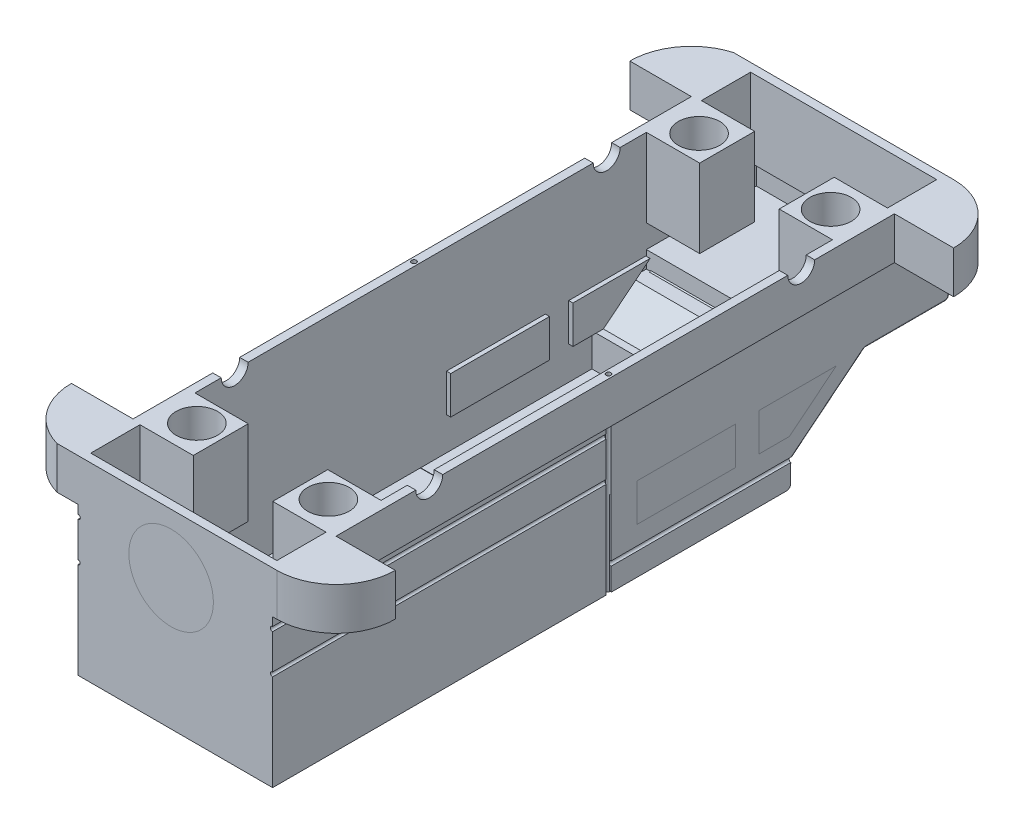
from build123d import *

# Parameters (mm, degrees)
BOSS_EXTRUDE1_DEPTH      = 12.7
SKETCH3_R                = 4.039553008
CUT_EXTRUDE1_DEPTH       = 80.451479119
SKETCH4_R                = 6.227777938
CUT_EXTRUDE3_DEPTH       = 25.4
SKETCH5_W                = 58.42
SKETCH5_H                = 101.6
BOSS_EXTRUDE2_DEPTH      = 19.05
SKETCH6_W                = 58.42
SKETCH6_H                = 76.2
BOSS_EXTRUDE3_DEPTH      = 25.4
FILLET1_R                = 1.27
SKETCH10_W               = 58.42
SKETCH10_H               = 101.6
BOSS_EXTRUDE4_DEPTH      = 19.05
SKETCH11_W               = 50.8
SKETCH11_H               = 91.44
CUT_EXTRUDE5_DEPTH       = 6.35
SKETCH12_W               = 55.88
SKETCH12_H               = 135.54394496
CUT_EXTRUDE6_DEPTH       = 20.32
SKETCH13_W               = 55.88
SKETCH13_H               = 14.77802752
CUT_EXTRUDE7_DEPTH       = 22.86
CUT_EXTRUDE8_DEPTH       = 79.181479119
SKETCH14_W               = 48.26
SKETCH14_H               = 43.785724941
CUT_EXTRUDE9_DEPTH       = 2.54
SKETCH15_W               = 55.88
SKETCH15_H               = 13.826247504
CUT_EXTRUDE10_DEPTH      = 15.24
SKETCH17_W               = 55.57516164
SKETCH17_H               = 46.325724976
CUT_EXTRUDE12_DEPTH      = 33.02
SKETCH20_W               = 55.57516164
SKETCH20_H               = 2.54
CUT_EXTRUDE13_DEPTH      = 15.24
CUT_EXTRUDE14_DEPTH      = 60.96
CUT_EXTRUDE15_DEPTH      = 79.181479119
SKETCH25_W               = 53.34
SKETCH25_H               = 23.50784169
BOSS_EXTRUDE9_DEPTH      = 2.54
BOSS_EXTRUDE10_DEPTH     = 2.54
BOSS_EXTRUDE11_DEPTH     = 2.54
SKETCH30_R               = 0.634743881
SKETCH30_R_2             = 0.669932812
CUT_EXTRUDE22_DEPTH      = 100.33
SKETCH33_R               = 0.704596327
CUT_EXTRUDE23_DEPTH      = 26.4
CUT_EXTRUDE23_DEPTH_BACK = 32.75
SKETCH34_R               = 0.682956923
CUT_EXTRUDE24_DEPTH      = 200.66
SKETCH29_W               = 29.660369153
SKETCH29_H               = 11.320366442
CUT_EXTRUDE25_DEPTH      = 79.181479119
SKETCH38_W               = 29.660369153
SKETCH38_H               = 11.320366442
BOSS_EXTRUDE13_DEPTH     = 2.54
SKETCH39_W               = 29.660369153
SKETCH39_H               = 11.320366442
BOSS_EXTRUDE14_DEPTH     = 2.54
FILLET2_R                = 2.54
FILLET4_R                = 0.254
FILLET5_R                = 1.27
FILLET6_R                = 1.27
SKETCH43_W               = 10.2616
SKETCH43_H               = 25.4
CUT_EXTRUDE30_DEPTH      = 0.508
FILLET7_R                = 0.508
FILLET8_R                = 0.508
BOSS_EXTRUDE15_DEPTH     = 25.4
SKETCH46_W               = 50.8
SKETCH46_H               = 93.865209379
CUT_EXTRUDE31_DEPTH      = 2.54
SKETCH47_R               = 0.704596327
SKETCH47_R_2             = 0.736772129
CUT_EXTRUDE32_DEPTH      = 58.1500001
SKETCH49_W               = 55.88
SKETCH49_H               = 72.85197248
CUT_EXTRUDE33_DEPTH      = 33.02
SKETCH50_W               = 23.876
SKETCH50_H               = 17.327803991
SKETCH50_H_2             = 8.072196009
CUT_EXTRUDE34_DEPTH      = 30.48
SKETCH53_W               = 52.29988828
SKETCH53_H               = 31.28802752
CUT_EXTRUDE37_DEPTH      = 21.59
SKETCH54_W               = 23.876
SKETCH54_H               = 22.86
CUT_EXTRUDE38_DEPTH      = 20.32
SKETCH55_W               = 55.88
SKETCH55_H               = 14.77802752
CUT_EXTRUDE39_DEPTH      = 30.48
SKETCH56_W               = 55.88
SKETCH56_H               = 6.942437751
CUT_EXTRUDE40_DEPTH      = 33.02
SKETCH57_W               = 55.88
SKETCH57_H               = 14.77802752
CUT_EXTRUDE41_DEPTH      = 5.08
SKETCH58_W               = 23.876
SKETCH58_H               = 16.51
CUT_EXTRUDE42_DEPTH      = 5.08
SKETCH59_R               = 12.7
CUT_EXTRUDE43_DEPTH      = 2.54
SKETCH60_R               = 12.7
BOSS_EXTRUDE17_DEPTH     = 2.54


with BuildPart() as part:
    # Sketch1 → Boss-Extrude1 (new body)
    with BuildSketch(Plane(origin=(0, 0, 0), x_dir=(1, 0, 0), z_dir=(0, 1, 0))):
        with BuildLine():
            Line((-24.894407518, 17.78), (41.145592482, 17.78))
            ThreePointArc((41.145592482, 17.78), (53.717951052, 12.572358569), (58.925592482, 0))
            Line((58.925592482, 0), (41.145592482, 0))
            Line((41.145592482, 0), (41.145592482, -167.64))
            Line((41.145592482, -167.64), (58.925592482, -167.64))
            ThreePointArc((58.925592482, -167.64), (53.717951052, -180.212358569), (41.145592482, -185.42))
            Line((41.145592482, -185.42), (-24.894407518, -185.42))
            ThreePointArc((-24.894407518, -185.42), (-34.577054874, -178.775485757), (-38.305886636, -167.64))
            Line((-38.305886636, -167.64), (-19.814407518, -167.64))
            Line((-19.814407518, -167.64), (-19.814407518, 0))
            Line((-19.814407518, 0), (-38.305886636, 0))
            ThreePointArc((-38.305886636, 0), (-34.577054874, 11.135485757), (-24.894407518, 17.78))
        make_face()
    extrude(amount=BOSS_EXTRUDE1_DEPTH)

    # Sketch3 → Cut-Extrude1 (cut, through all)
    with BuildSketch(Plane(origin=(41.145592482, 0, 0), x_dir=(0, 0, -1), z_dir=(1, 0, 0))):
        with Locations((-139.663754312, 12.7)):
            Circle(SKETCH3_R)
        with Locations((-27.973876463, 12.7)):
            Circle(SKETCH3_R)
    extrude(amount=-CUT_EXTRUDE1_DEPTH, mode=Mode.SUBTRACT)

    # Sketch4 → Cut-Extrude3 (cut)
    with BuildSketch(Plane(origin=(0, 12.7, 0), x_dir=(1, 0, 0), z_dir=(0, 1, 0))):
        with Locations((30.41662766, -8.42802752)):
            Circle(SKETCH4_R)
        with Locations((30.41662766, -159.21197248)):
            Circle(SKETCH4_R)
        with Locations((-9.085442695, -159.21197248)):
            Circle(SKETCH4_R)
        with Locations((-9.085442695, -8.42802752)):
            Circle(SKETCH4_R)
    extrude(amount=-CUT_EXTRUDE3_DEPTH, mode=Mode.SUBTRACT)

    # Sketch5 → Boss-Extrude2 (add)
    with BuildSketch(Plane(origin=(0, 0, 0), x_dir=(-1, 0, 0), z_dir=(0, -1, 0))):
        with Locations((-10.665592482, -33.02)):
            Rectangle(SKETCH5_W, SKETCH5_H)
    extrude(amount=BOSS_EXTRUDE2_DEPTH)

    # Sketch6 → Boss-Extrude3 (add)
    with BuildSketch(Plane.XZ.offset(19.05)):
        with Locations((10.665592482, 45.72)):
            Rectangle(SKETCH6_W, SKETCH6_H)
    extrude(amount=BOSS_EXTRUDE3_DEPTH)

    # Fillet1
    fillet1_edges = [part.edges().sort_by_distance(p)[0] for p in [
        (10.665592482, -19.05, -17.78),
    ]]
    fillet(fillet1_edges, radius=FILLET1_R)

    # Sketch10 → Boss-Extrude4 (add)
    with BuildSketch(Plane(origin=(0, 0, 0), x_dir=(-1, 0, 0), z_dir=(0, -1, 0))):
        with Locations((-10.665592482, -134.62)):
            Rectangle(SKETCH10_W, SKETCH10_H)
    extrude(amount=BOSS_EXTRUDE4_DEPTH)

    # Sketch11 → Cut-Extrude5 (cut, symmetric)
    with BuildSketch(Plane.XZ.offset(19.05)):
        with Locations((10.665592482, 134.62)):
            Rectangle(SKETCH11_W, SKETCH11_H)
    extrude(amount=CUT_EXTRUDE5_DEPTH, both=True, mode=Mode.SUBTRACT)

    # Sketch12 → Cut-Extrude6 (cut)
    with BuildSketch(Plane(origin=(0, 12.7, 0), x_dir=(1, 0, 0), z_dir=(0, 1, 0))):
        with Locations((10.665592482, -83.82)):
            Rectangle(SKETCH12_W, SKETCH12_H)
    extrude(amount=-CUT_EXTRUDE6_DEPTH, mode=Mode.SUBTRACT)

    # Sketch13 → Cut-Extrude7 (cut, symmetric)
    with BuildSketch(Plane(origin=(0, 12.7, 0), x_dir=(1, 0, 0), z_dir=(0, 1, 0))):
        with Locations((10.665592482, 7.85098624)):
            Rectangle(SKETCH13_W, SKETCH13_H)
        with Locations((10.665592482, -175.49098624)):
            Rectangle(SKETCH13_W, SKETCH13_H)
    extrude(amount=CUT_EXTRUDE7_DEPTH, both=True, mode=Mode.SUBTRACT)

    # Sketch7 → Cut-Extrude8 (cut, through all)
    with BuildSketch(Plane(origin=(39.875592482, 0, 0), x_dir=(0, 0, -1), z_dir=(1, 0, 0))):
        Polygon((-7.62, -19.05), (-29.874275059, -36.994690972), (-29.874275059, -44.45), (-7.62, -44.45), align=None)
    extrude(amount=-CUT_EXTRUDE8_DEPTH, mode=Mode.SUBTRACT)

    # Sketch14 → Cut-Extrude9 (cut, symmetric)
    with BuildSketch(Plane.XZ.offset(44.45)):
        with Locations((10.665592482, 56.84713753)):
            Rectangle(SKETCH14_W, SKETCH14_H)
    extrude(amount=CUT_EXTRUDE9_DEPTH, both=True, mode=Mode.SUBTRACT)

    # Sketch15 → Cut-Extrude10 (cut)
    with BuildSketch(Plane(origin=(0, -7.62, 0), x_dir=(1, 0, 0), z_dir=(0, 1, 0))):
        with Locations((10.665592482, -22.961151272)):
            Rectangle(SKETCH15_W, SKETCH15_H)
    extrude(amount=-CUT_EXTRUDE10_DEPTH, mode=Mode.SUBTRACT)

    # Sketch17 → Cut-Extrude12 (cut)
    with BuildSketch(Plane(origin=(0, -7.62, 0), x_dir=(1, 0, 0), z_dir=(0, 1, 0))):
        with Locations((10.513173302, -55.577137512)):
            Rectangle(SKETCH17_W, SKETCH17_H)
    extrude(amount=-CUT_EXTRUDE12_DEPTH, mode=Mode.SUBTRACT)

    # Sketch20 → Cut-Extrude13 (cut)
    with BuildSketch(Plane(origin=(0, -7.62, 0), x_dir=(1, 0, 0), z_dir=(0, 1, 0))):
        with Locations((10.513173302, -31.144275024)):
            Rectangle(SKETCH20_W, SKETCH20_H)
    extrude(amount=-CUT_EXTRUDE13_DEPTH, mode=Mode.SUBTRACT)

    # Sketch21 → Cut-Extrude14 (cut)
    with BuildSketch(Plane(origin=(39.875592482, 0, 0), x_dir=(0, 0, -1), z_dir=(1, 0, 0))):
        Polygon((-30.235058944, -30.705184577), (-16.196001434, -19.384818135), (-39.363214184, -19.384818135), align=None)
    extrude(amount=-CUT_EXTRUDE14_DEPTH, mode=Mode.SUBTRACT)

    # Sketch22 → Cut-Extrude15 (cut, through all)
    with BuildSketch(Plane(origin=(39.875592482, 0, 0), x_dir=(0, 0, -1), z_dir=(1, 0, 0))):
        Polygon((-39.363214184, -19.384818135), (-39.363214184, -30.705184577), (-30.235058944, -30.705184577), align=None)
    extrude(amount=-CUT_EXTRUDE15_DEPTH, mode=Mode.SUBTRACT)

    # Sketch30 → Cut-Extrude22 (cut, symmetric)
    with BuildSketch(Plane.XY.offset(185.42)):
        with Locations((39.875592482, -14.996123555)):
            Circle(SKETCH30_R)
        with Locations((39.875592482, -3.218296259)):
            Circle(SKETCH30_R_2)
        with Locations((-18.544407518, -14.996123555)):
            Circle(SKETCH30_R)
        with Locations((-18.544407518, -3.218296259)):
            Circle(SKETCH30_R_2)
    extrude(amount=CUT_EXTRUDE22_DEPTH, both=True, mode=Mode.SUBTRACT)

    # Sketch33 → Cut-Extrude23 (cut, two sides)
    with BuildSketch(Plane.XZ.offset(19.05)) as cut_extrude23_sk:
        with Locations((39.875592482, 84.582)):
            Circle(SKETCH33_R)
        with Locations((-18.544407518, 84.582)):
            Circle(SKETCH33_R)
    extrude(amount=CUT_EXTRUDE23_DEPTH, mode=Mode.SUBTRACT)
    extrude(cut_extrude23_sk.sketch, amount=-CUT_EXTRUDE23_DEPTH_BACK, mode=Mode.SUBTRACT)

    # Sketch34 → Cut-Extrude24 (cut)
    with BuildSketch(Plane.XY.offset(83.82)):
        with Locations((39.875592482, -36.994690972)):
            Circle(SKETCH34_R)
        with Locations((-18.544407518, -36.994690972)):
            Circle(SKETCH34_R)
    extrude(amount=-CUT_EXTRUDE24_DEPTH, mode=Mode.SUBTRACT)

    # Sketch29 → Cut-Extrude25 (cut, through all)
    with BuildSketch(Plane(origin=(39.875592482, 0, 0), x_dir=(0, 0, -1), z_dir=(1, 0, 0))):
        with Locations((-61.243626695, -25.045001356)):
            Rectangle(SKETCH29_W, SKETCH29_H)
    extrude(amount=-CUT_EXTRUDE25_DEPTH, mode=Mode.SUBTRACT)

    # Fillet2
    fillet2_edges = [part.edges().sort_by_distance(p)[0] for p in [
        (10.665592482, -36.994690972, 29.874275059),
    ]]
    fillet(fillet2_edges, radius=FILLET2_R)

    # Fillet4
    fillet4_edges = [part.edges().sort_by_distance(p)[0] for p in [
        (10.665592482, -44.45, 83.82),
    ]]
    fillet(fillet4_edges, radius=FILLET4_R)

    # Fillet5
    fillet5_edges = [part.edges().sort_by_distance(p)[0] for p in [
        (10.665592482, -44.45, 29.874275059),
    ]]
    fillet(fillet5_edges, radius=FILLET5_R)

    # Fillet6
    fillet6_edges = [part.edges().sort_by_distance(p)[0] for p in [
        (10.665592482, -19.05, 7.62),
    ]]
    fillet(fillet6_edges, radius=FILLET6_R)

    # Sketch43 → Cut-Extrude30 (cut)
    with BuildSketch(Plane(origin=(0, 0, -17.78), x_dir=(-1, 0, 0), z_dir=(0, 0, -1))):
        with Locations((-32.204792482, -2.54)):
            Rectangle(SKETCH43_W, SKETCH43_H)
        with Locations((-17.726792482, -2.54)):
            Rectangle(SKETCH43_W, SKETCH43_H)
        with Locations((-3.248792482, -2.54)):
            Rectangle(SKETCH43_W, SKETCH43_H)
        with Locations((11.229207518, -2.54)):
            Rectangle(SKETCH43_W, SKETCH43_H)
    extrude(amount=-CUT_EXTRUDE30_DEPTH, mode=Mode.SUBTRACT)

    # Fillet7
    fillet7_edges = [part.edges().sort_by_distance(p)[0] for p in [
        (39.875592482, -8.89, -17.78),
        (39.875592482, -19.05, -4.669122824),
        (39.875592482, -18.678025612, -17.408025612),
        (39.875592482, -36.271389048, 28.976077738),
        (39.875592482, -27.781773584, 18.448790052),
        (39.875592482, -19.12240534, 7.594444584),
    ]]
    fillet(fillet7_edges, radius=FILLET7_R)

    # Fillet8
    fillet8_edges = [part.edges().sort_by_distance(p)[0] for p in [
        (-18.544407518, -8.89, -17.78),
        (-18.544407518, -18.678025612, -17.408025612),
        (-18.544407518, -36.271389048, 28.976077738),
        (-18.544407518, -27.781773584, 18.448790052),
        (-18.544407518, -19.12240534, 7.594444584),
        (-18.544407518, -19.05, -4.669122824),
    ]]
    fillet(fillet8_edges, radius=FILLET8_R)

    # Sketch45 → Boss-Extrude15 (add)
    with BuildSketch(Plane(origin=(0, -19.05, 0), x_dir=(-1, 0, 0), z_dir=(0, -1, 0))):
        Polygon((-39.875592482, -185.42), (17.909663637, -185.42), (18.544407518, -185.42), (18.544407518, -83.934790621), (-39.875592482, -83.934790621), (-39.875592482, -84.582), align=None)
    extrude(amount=BOSS_EXTRUDE15_DEPTH)

    # Sketch46 → Cut-Extrude31 (cut)
    with BuildSketch(Plane.XZ.offset(44.45)):
        with Locations((10.665592482, 134.677395311)):
            Rectangle(SKETCH46_W, SKETCH46_H)
    extrude(amount=-CUT_EXTRUDE31_DEPTH, mode=Mode.SUBTRACT)

    # Sketch47 → Cut-Extrude32 (cut, through all)
    with BuildSketch(Plane(origin=(0, -44.45, 0), x_dir=(-1, 0, 0), z_dir=(0, -1, 0))):
        with Locations((-39.875592482, -84.582)):
            Circle(SKETCH47_R)
        with Locations((18.544407518, -84.582)):
            Circle(SKETCH47_R_2)
    extrude(amount=-CUT_EXTRUDE32_DEPTH, mode=Mode.SUBTRACT)

    # Sketch49 → Cut-Extrude33 (cut)
    with BuildSketch(Plane(origin=(0, -7.62, 0), x_dir=(1, 0, 0), z_dir=(0, 1, 0))):
        with Locations((10.665592482, -115.16598624)):
            Rectangle(SKETCH49_W, SKETCH49_H)
    extrude(amount=-CUT_EXTRUDE33_DEPTH, mode=Mode.SUBTRACT)

    # Sketch50 → Cut-Extrude34 (cut)
    with BuildSketch(Plane(origin=(0, 0, 151.59197248), x_dir=(-1, 0, 0), z_dir=(0, 0, -1))):
        with Locations((-10.665592482, 4.036098005)):
            Rectangle(SKETCH50_W, SKETCH50_H)
        with Locations((-10.665592482, -8.663901996)):
            Rectangle(SKETCH50_W, SKETCH50_H_2)
    extrude(amount=-CUT_EXTRUDE34_DEPTH, mode=Mode.SUBTRACT)

    # Sketch53 → Cut-Extrude37 (cut)
    with BuildSketch(Plane(origin=(0, -19.05, 0), x_dir=(1, 0, 0), z_dir=(0, 1, 0))):
        with Locations((11.523690752, -167.23598624)):
            Rectangle(SKETCH53_W, SKETCH53_H)
    extrude(amount=-CUT_EXTRUDE37_DEPTH, mode=Mode.SUBTRACT)

    # Sketch54 → Cut-Extrude38 (cut)
    with BuildSketch(Plane(origin=(0, 0, -0.46197248), x_dir=(-1, 0, 0), z_dir=(0, 0, -1))):
        with Locations((-10.665592482, 1.27)):
            Rectangle(SKETCH54_W, SKETCH54_H)
    extrude(amount=-CUT_EXTRUDE38_DEPTH, mode=Mode.SUBTRACT)

    # Sketch55 → Cut-Extrude39 (cut)
    with BuildSketch(Plane(origin=(0, -10.16, 0), x_dir=(1, 0, 0), z_dir=(0, 1, 0))):
        with Locations((10.665592482, -175.49098624)):
            Rectangle(SKETCH55_W, SKETCH55_H)
    extrude(amount=-CUT_EXTRUDE39_DEPTH, mode=Mode.SUBTRACT)

    # Sketch56 → Cut-Extrude40 (cut)
    with BuildSketch(Plane.XY.offset(16.04802752)):
        with Locations((10.665592482, -14.308781125)):
            Rectangle(SKETCH56_W, SKETCH56_H)
    extrude(amount=-CUT_EXTRUDE40_DEPTH, mode=Mode.SUBTRACT)

    # Sketch57 → Cut-Extrude41 (cut)
    with BuildSketch(Plane(origin=(0, -10.16, 0), x_dir=(1, 0, 0), z_dir=(0, 1, 0))):
        with Locations((10.665592482, 7.85098624)):
            Rectangle(SKETCH57_W, SKETCH57_H)
    extrude(amount=-CUT_EXTRUDE41_DEPTH, mode=Mode.SUBTRACT)

    # Sketch58 → Cut-Extrude42 (cut)
    with BuildSketch(Plane(origin=(0, -10.16, 0), x_dir=(1, 0, 0), z_dir=(0, 1, 0))):
        with Locations((10.665592482, -7.79302752)):
            Rectangle(SKETCH58_W, SKETCH58_H)
    extrude(amount=-CUT_EXTRUDE42_DEPTH, mode=Mode.SUBTRACT)

    # Sketch59 → Cut-Extrude43 (cut)
    with BuildSketch(Plane.XY.offset(185.42)):
        with Locations((9.395592482, -5.146553975)):
            Circle(SKETCH59_R)
    extrude(amount=-CUT_EXTRUDE43_DEPTH, mode=Mode.SUBTRACT)


with BuildPart() as body_2:
    # Sketch25 → Boss-Extrude9 (new body)
    with BuildSketch(Plane(origin=(0, -7.82065824, -6.306172407), x_dir=(1, 0, 0), z_dir=(0, -0.778452438, -0.627703594))):
        with Locations((10.665592482, 32.183481887)):
            Rectangle(SKETCH25_W, SKETCH25_H)
    extrude(amount=-BOSS_EXTRUDE9_DEPTH)


with BuildPart() as body_3:
    # Sketch26 → Boss-Extrude10 (new body)
    with BuildSketch(Plane.ZY.offset(18.544407518)):
        Polygon((16.196001434, -19.384818135), (39.363214184, -19.384818135), (39.363214184, -30.705184577), (30.235058944, -30.705184577), align=None)
    extrude(amount=-BOSS_EXTRUDE10_DEPTH)


with BuildPart() as body_4:
    # Sketch27 → Boss-Extrude11 (new body)
    with BuildSketch(Plane(origin=(39.875592482, 0, 0), x_dir=(0, 0, -1), z_dir=(1, 0, 0))):
        Polygon((-39.363214184, -19.384818135), (-16.196001434, -19.384818135), (-30.235058944, -30.705184577), (-39.363214184, -30.705184577), align=None)
    extrude(amount=-BOSS_EXTRUDE11_DEPTH)


with BuildPart() as body_5:
    # Sketch38 → Boss-Extrude13 (new body)
    with BuildSketch(Plane(origin=(39.875592482, 0, 0), x_dir=(0, 0, -1), z_dir=(1, 0, 0))):
        with Locations((-61.243626695, -25.045001356)):
            Rectangle(SKETCH38_W, SKETCH38_H)
    extrude(amount=-BOSS_EXTRUDE13_DEPTH)


with BuildPart() as body_6:
    # Sketch39 → Boss-Extrude14 (new body)
    with BuildSketch(Plane.ZY.offset(18.544407518)):
        with Locations((61.243626695, -25.045001356)):
            Rectangle(SKETCH39_W, SKETCH39_H)
    extrude(amount=-BOSS_EXTRUDE14_DEPTH)


with BuildPart() as body_7:
    # Sketch60 → Boss-Extrude17 (new body)
    with BuildSketch(Plane.XY.offset(185.42)):
        with Locations((9.395592482, -5.146553975)):
            Circle(SKETCH60_R)
    extrude(amount=-BOSS_EXTRUDE17_DEPTH)


solid = Compound([part.part, body_2.part, body_3.part, body_4.part, body_5.part, body_6.part, body_7.part])
